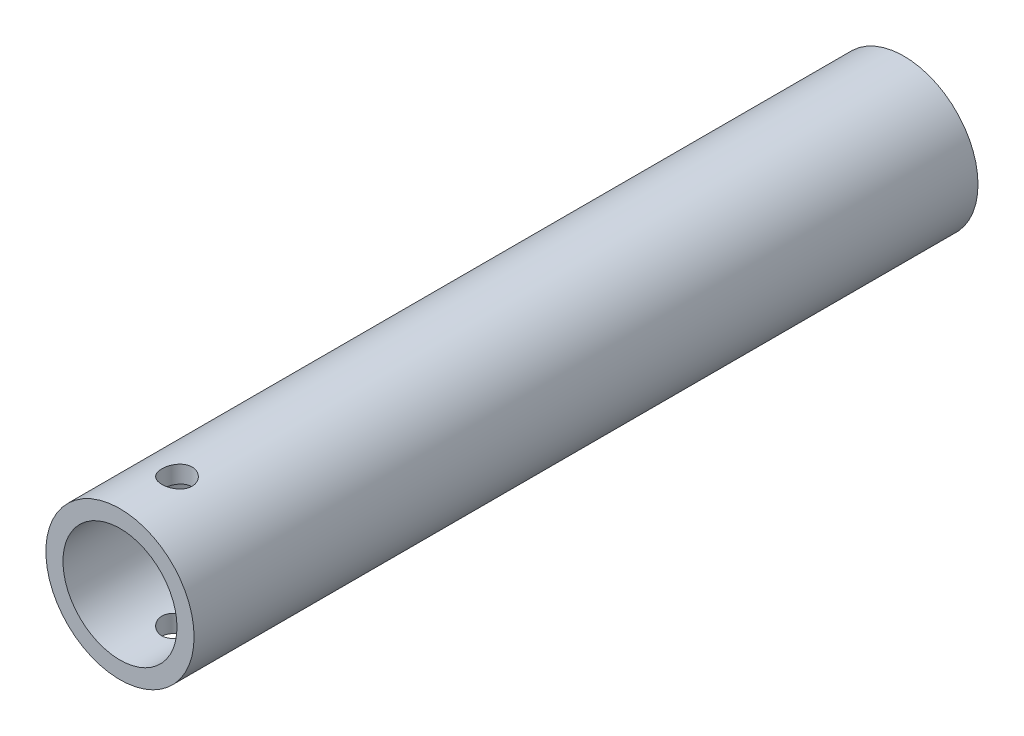
from build123d import *

# Parameters (mm, degrees)
SKETCH1_R               = 13
SKETCH1_R_2             = 10
BOSS_EXTRUDE1_DEPTH     = 137.5
SKETCH3_R               = 2.5
CUT_EXTRUDE1_DEPTH      = 139.723646146
CUT_EXTRUDE2_DEPTH      = 150
CUT_EXTRUDE2_DEPTH_BACK = 139.723646264
SKETCH4_R               = 2.65


with BuildPart() as part:
    # Sketch1 → Boss-Extrude1 (new body)
    with BuildSketch(Plane.XY):
        Circle(SKETCH1_R)
        Circle(SKETCH1_R_2, mode=Mode.SUBTRACT)
    extrude(amount=BOSS_EXTRUDE1_DEPTH)

    # Sketch3 → Cut-Extrude1 (cut, through all)
    with BuildSketch(Plane(origin=(0, 0, 0), x_dir=(1, 0, 0), z_dir=(0, 1, 0))):
        with Locations((0, -10)):
            Circle(SKETCH3_R)
        with Locations((0, -20)):
            Circle(SKETCH3_R)
    extrude(amount=-CUT_EXTRUDE1_DEPTH, mode=Mode.SUBTRACT)

    # Sketch4 → Cut-Extrude2 (cut, two sides: drawn at the far end of the back side and taken through both)
    with BuildSketch(Plane(origin=(0, 0, 0), x_dir=(0, 0, -1), z_dir=(0, 1, 0)).offset(-CUT_EXTRUDE2_DEPTH_BACK)):
        with Locations((-127.5, 0)):
            Circle(SKETCH4_R)
    extrude(amount=CUT_EXTRUDE2_DEPTH + CUT_EXTRUDE2_DEPTH_BACK, mode=Mode.SUBTRACT)


solid = part.part
